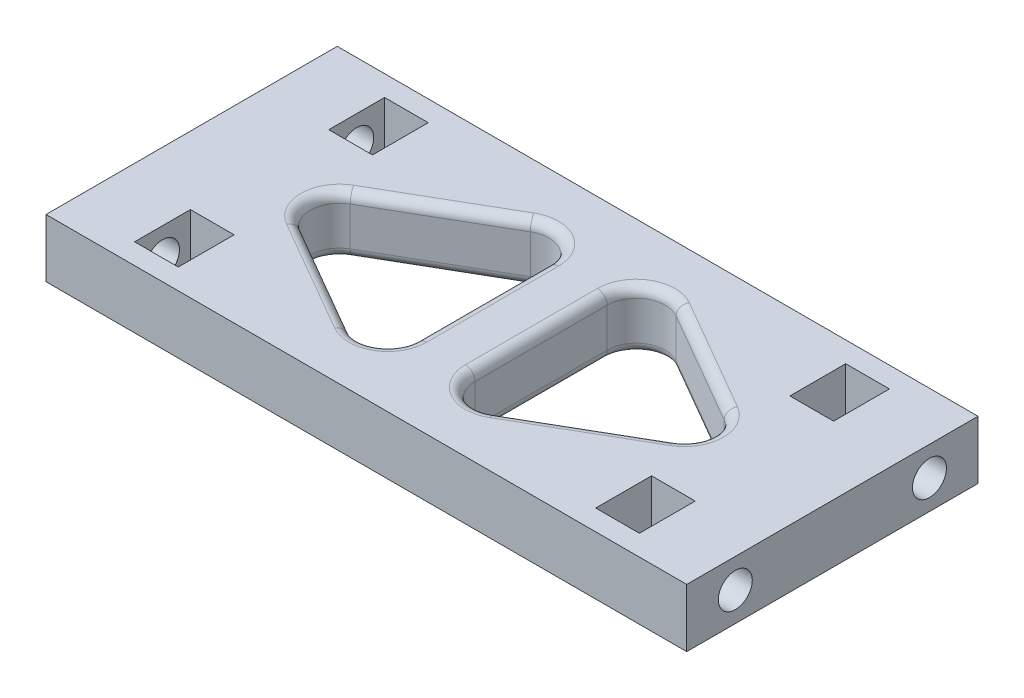
from build123d import *

# Parameters (mm, degrees)
SKETCH1_W           = 30
SKETCH1_H           = 6
BOSS_EXTRUDE1_DEPTH = 33
SKETCH2_R           = 1.75
CUT_EXTRUDE1_DEPTH  = 7
CUT_EXTRUDE2_DEPTH  = 4.5
CUT_EXTRUDE3_DEPTH  = 7
FILLET1_R           = 3
FILLET2_R           = 1
FILLET3_R           = 0.5


with BuildPart() as part:
    # Sketch1 → Boss-Extrude1 (new body, symmetric)
    with BuildSketch(Plane(origin=(0, 0, 0), x_dir=(0, 0, -1), z_dir=(1, 0, 0))):
        Rectangle(SKETCH1_W, SKETCH1_H)
    extrude(amount=BOSS_EXTRUDE1_DEPTH, both=True)

    # Sketch2 → Cut-Extrude1 (cut)
    with BuildSketch(Plane(origin=(33, 0, 0), x_dir=(0, 0, -1), z_dir=(1, 0, 0))):
        with Locations((-10, 0)):
            Circle(SKETCH2_R)
        with Locations((10, 0)):
            Circle(SKETCH2_R)
    cut_extrude1 = extrude(amount=-CUT_EXTRUDE1_DEPTH, mode=Mode.SUBTRACT)

    # Sketch3 → Cut-Extrude2 (cut)
    with BuildSketch(Plane(origin=(26, 0, 0), x_dir=(0, 0, -1), z_dir=(1, 0, 0))):
        Polygon((-12.875, 3), (-12.875, 1.659882024), (-10.553847577, 3), align=None)
        Polygon((-10.553847577, 3), (-12.875, 1.659882024), (-12.875, -1.659882024), (-10, -3.319764048), (-7.125, -1.659882024), (-7.125, 1.659882024), (-9.446152423, 3), align=None)
        Polygon((-10, 3.319764048), (-10.553847577, 3), (-9.446152423, 3), align=None)
        Polygon((-7.125, 3), (-9.446152423, 3), (-7.125, 1.659882024), align=None)
        Polygon((12.875, 3), (7.125, 3), (7.125, 1.659882024), (7.125, -1.659882024), (10, -3.319764048), (12.875, -1.659882024), (12.875, 1.659882024), align=None)
    cut_extrude2 = extrude(amount=-CUT_EXTRUDE2_DEPTH, mode=Mode.SUBTRACT)

    # Mirror1: Cut-Extrude1, Cut-Extrude2 across plane
    add(cut_extrude1.mirror(Plane(origin=(0, 0, 0), x_dir=(0, 0, 1), z_dir=(1, 0, 0))), mode=Mode.SUBTRACT)
    add(cut_extrude2.mirror(Plane(origin=(0, 0, 0), x_dir=(0, 0, 1), z_dir=(1, 0, 0))), mode=Mode.SUBTRACT)

    # Sketch4 → Cut-Extrude3 (cut, through all)
    with BuildSketch(Plane(origin=(0, 3, 0), x_dir=(1, 0, 0), z_dir=(0, 1, 0))):
        Polygon((-3, -12), (-3, 12), (-23.75, 0), align=None)
        Polygon((23.75, 0), (3, 12), (3, -12), align=None)
    extrude(amount=-CUT_EXTRUDE3_DEPTH, mode=Mode.SUBTRACT)

    # Fillet1
    fillet1_edges = [part.edges().sort_by_distance(p)[0] for p in [
        (-23.75, 0, 0),
        (-3, 0, -12),
        (-3, 0, 12),
        (23.75, 0, 0),
        (3, 0, 12),
        (3, 0, -12),
    ]]
    fillet(fillet1_edges, radius=FILLET1_R)

    # Fillet2
    fillet2_edges = [part.edges().sort_by_distance(p)[0] for p in [
        (13.380621084, 3, -5.996749253),
        (13.380621084, -3, -5.996749253),
        (13.380621084, 3, 5.996749253),
        (13.380621084, -3, 5.996749253),
        (3, 3, 0),
        (3, -3, 0),
        (-3, 3, 0),
        (-3, -3, 0),
        (-13.380621084, 3, 5.996749253),
        (-13.380621084, -3, 5.996749253),
        (-13.380621084, 3, -5.996749253),
        (-13.380621084, -3, -5.996749253),
        (20.757491656, 3, 0),
        (20.757491656, -3, 0),
        (4.500937921, 3, 9.398130742),
        (4.500937921, -3, 9.398130742),
        (4.500937921, 3, -9.398130742),
        (4.500937921, -3, -9.398130742),
        (-4.500937921, 3, 9.398130742),
        (-4.500937921, -3, 9.398130742),
        (-20.757491656, 3, 0),
        (-20.757491656, -3, 0),
        (-4.500937921, 3, -9.398130742),
        (-4.500937921, -3, -9.398130742),
    ]]
    fillet(fillet2_edges, radius=FILLET2_R)

    # Fillet3
    fillet3_edges = [part.edges().sort_by_distance(p)[0] for p in [
        (23.75, -3, 10.553847577),
        (23.75, -3, 9.446152423),
        (23.75, -3, -9.446152423),
        (23.75, -3, -10.553847577),
        (-23.75, -3, 9.446152423),
        (-23.75, -3, 10.553847577),
        (-23.75, -3, -10.553847577),
        (-23.75, -3, -9.446152423),
    ]]
    fillet(fillet3_edges, radius=FILLET3_R)


solid = part.part
